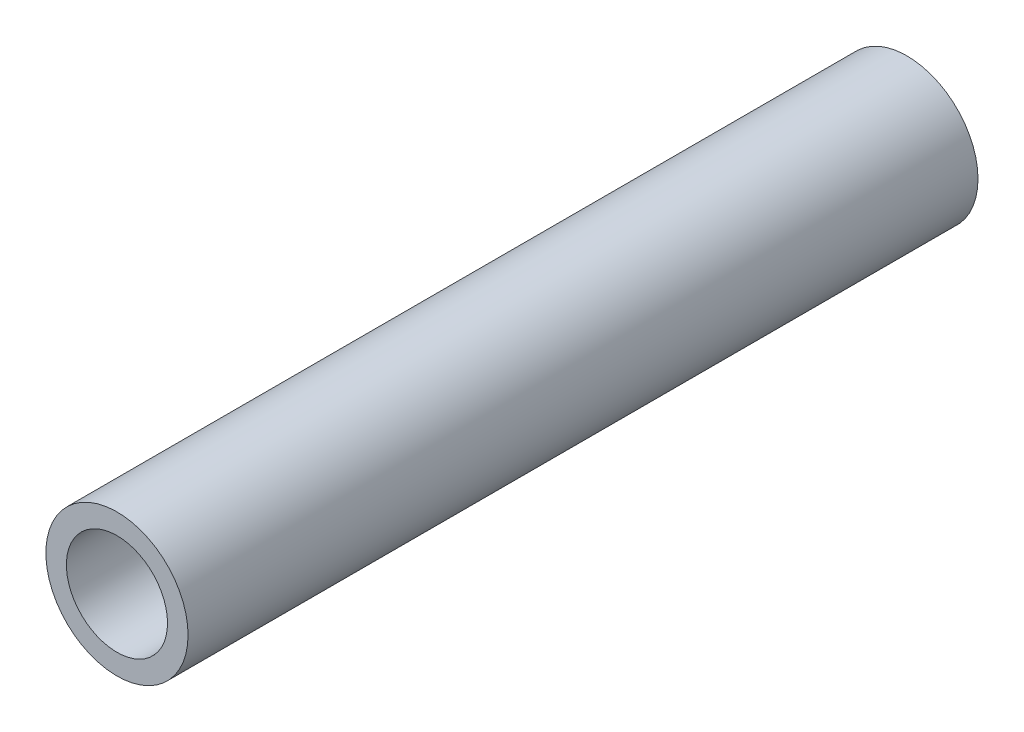
from build123d import *

# Parameters (mm, degrees)
SKETCH1_R      = 2.25
SKETCH1_R_2    = 1.6
EXTRUDE1_DEPTH = 12.5


with BuildPart() as part:
    # Sketch1 → Extrude1 (new body, symmetric)
    with BuildSketch(Plane.XY):
        Circle(SKETCH1_R)
        Circle(SKETCH1_R_2, mode=Mode.SUBTRACT)
    extrude(amount=EXTRUDE1_DEPTH, both=True)


solid = part.part
